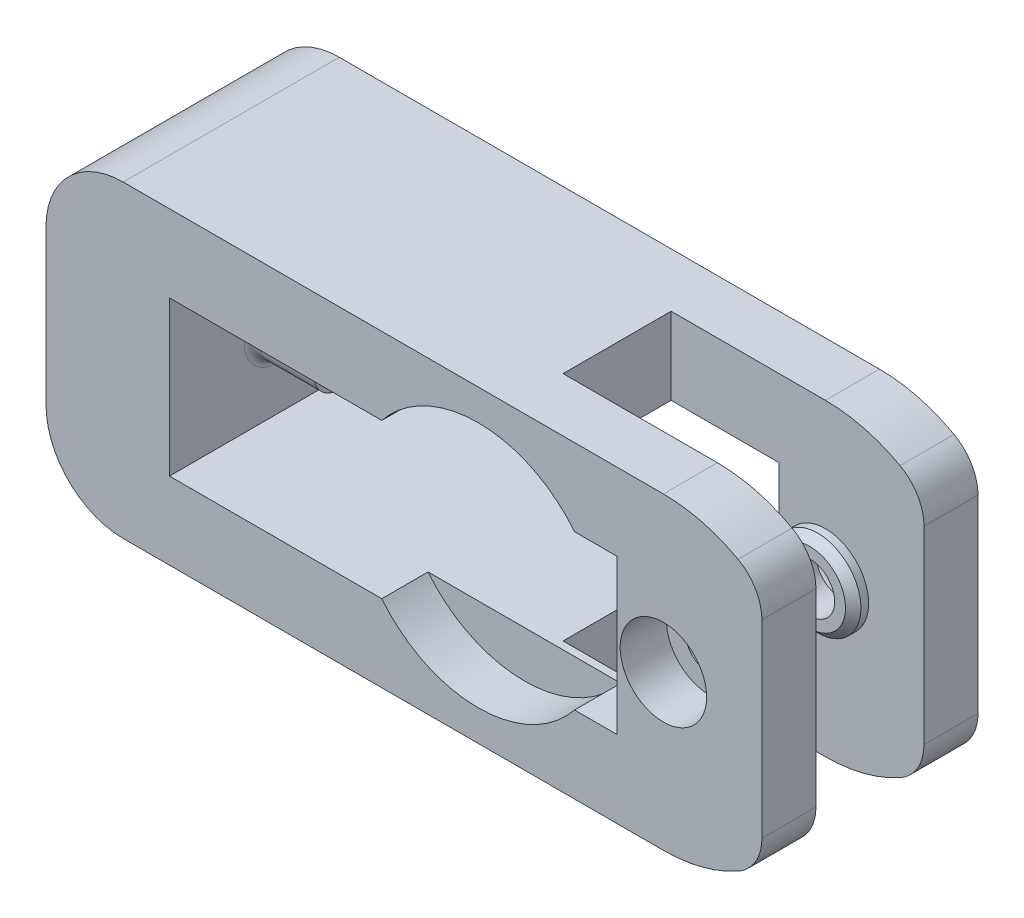
from build123d import *

# Parameters (mm, degrees)
Y_KSEKLIK_EKSTR_ZYON1_DEPTH = 14
RADYUS1_R                   = 5
IZIM3_W                     = 10
IZIM3_H                     = 7
KES_EKSTR_ZYON2_DEPTH       = 20
Y_KSEKLIK_EKSTR_ZYON2_DEPTH = 3.5
Y_KSEKLIK_EKSTR_ZYON3_DEPTH = 3.5
IZIM6_R                     = 2.8
IZIM6_R_2                   = 1.6
Y_KSEKLIK_EKSTR_ZYON4_DEPTH = 1
IZIM7_R                     = 2.8
IZIM7_R_2                   = 1.6
Y_KSEKLIK_EKSTR_ZYON5_DEPTH = 1
PAH1_SIZE                   = 0.5
IZIM8_W                     = 29
IZIM8_H                     = 10
KES_EKSTR_ZYON3_DEPTH       = 15
IZIM9_R                     = 2.8
KES_EKSTR_ZYON5_DEPTH       = 3
KES_EKSTR_ZYON6_DEPTH       = 2.5
IZIM11_R                    = 1.6
KES_EKSTR_ZYON7_DEPTH       = 10
IZIM12_R                    = 1.65
Y_KSEKLIK_EKSTR_ZYON6_DEPTH = 4
RADYUS2_R                   = 0.5
RADYUS5_R                   = 1
RADYUS7_R                   = 3
IZIM15_R                    = 8
KES_EKSTR_ZYON8_DEPTH       = 3


with BuildPart() as part:
    # Çizim1 → Yükseklik-Ekstrüzyon1 (new body)
    with BuildSketch(Plane.XY):
        Polygon((-28.371919233, 20), (11.628080767, 20), (11.628080767, 15), (-20.371919233, 15), (-20.371919233, 5), (11.628080767, 5), (11.628080767, 0), (-28.371919233, 0), align=None)
    extrude(amount=Y_KSEKLIK_EKSTR_ZYON1_DEPTH)

    # Radyus1
    radyus1_edges = [part.edges().sort_by_distance(p)[0] for p in [
        (-28.371919233, 20, 7),
        (-28.371919233, 0, 7),
    ]]
    fillet(radyus1_edges, radius=RADYUS1_R)

    # Çizim3 → Kes-Ekstrüzyon2 (cut)
    with BuildSketch(Plane(origin=(0, 20, 0), x_dir=(1, 0, 0), z_dir=(0, 1, 0))):
        with Locations((6.628080767, -7)):
            Rectangle(IZIM3_W, IZIM3_H)
    extrude(amount=-KES_EKSTR_ZYON2_DEPTH, mode=Mode.SUBTRACT)

    # Çizim4 → Yükseklik-Ekstrüzyon2 (add)
    with BuildSketch(Plane.XY.offset(14)):
        with BuildLine():
            Line((18.011958757, 17.69714894), (18.011958757, 2.30285106))
            ThreePointArc((18.011958757, 2.30285106), (1.628080767, 10), (18.011958757, 17.69714894))
        make_face()
    extrude(amount=-Y_KSEKLIK_EKSTR_ZYON2_DEPTH)

    # Çizim5 → Yükseklik-Ekstrüzyon3 (add)
    with BuildSketch(Plane(origin=(0, 0, 0), x_dir=(-1, 0, 0), z_dir=(0, 0, -1))):
        with BuildLine():
            Line((-18.011958757, 17.69714894), (-18.011958757, 2.30285106))
            ThreePointArc((-18.011958757, 2.30285106), (-1.628080767, 10), (-18.011958757, 17.69714894))
        make_face()
    extrude(amount=-Y_KSEKLIK_EKSTR_ZYON3_DEPTH)

    # Çizim6 → Yükseklik-Ekstrüzyon4 (add)
    with BuildSketch(Plane(origin=(0, 0, 10.5), x_dir=(-1, 0, 0), z_dir=(0, 0, -1))):
        with Locations((-11.628080767, 10)):
            Circle(IZIM6_R)
        with Locations((-11.628080767, 10)):
            Circle(IZIM6_R_2, mode=Mode.SUBTRACT)
    extrude(amount=Y_KSEKLIK_EKSTR_ZYON4_DEPTH)

    # Çizim7 → Yükseklik-Ekstrüzyon5 (add)
    with BuildSketch(Plane.XY.offset(3.5)):
        with Locations((11.628080767, 10)):
            Circle(IZIM7_R)
        with Locations((11.628080767, 10)):
            Circle(IZIM7_R_2, mode=Mode.SUBTRACT)
    extrude(amount=Y_KSEKLIK_EKSTR_ZYON5_DEPTH)

    # Pah1
    pah1_edges = [part.edges().sort_by_distance(p)[0] for p in [
        (14.428080767, 10, 9.5),
        (8.828080767, 10, 4.5),
    ]]
    chamfer(pah1_edges, length=PAH1_SIZE)

    # Çizim8 → Kes-Ekstrüzyon3 (cut)
    with BuildSketch(Plane.XY.offset(14)):
        with Locations((-5.871919233, 10)):
            Rectangle(IZIM8_W, IZIM8_H)
    extrude(amount=-KES_EKSTR_ZYON3_DEPTH, mode=Mode.SUBTRACT)

    # Çizim9 → Kes-Ekstrüzyon5 (cut)
    with BuildSketch(Plane.XY.offset(14)):
        with Locations((11.628080767, 10)):
            Circle(IZIM9_R)
    extrude(amount=-KES_EKSTR_ZYON5_DEPTH, mode=Mode.SUBTRACT)

    # Çizim10 → Kes-Ekstrüzyon6 (cut)
    with BuildSketch(Plane(origin=(0, 0, 0), x_dir=(-1, 0, 0), z_dir=(0, 0, -1))):
        Polygon((-11.628080767, 13.15), (-14.356060789, 11.575), (-14.356060789, 8.425), (-11.628080767, 6.85), (-8.900100745, 8.425), (-8.900100745, 11.575), align=None)
    extrude(amount=-KES_EKSTR_ZYON6_DEPTH, mode=Mode.SUBTRACT)

    # Çizim11 → Kes-Ekstrüzyon7 (cut)
    with BuildSketch(Plane.XY.offset(11)):
        with Locations((11.628080767, 10)):
            Circle(IZIM11_R)
    extrude(amount=-KES_EKSTR_ZYON7_DEPTH, mode=Mode.SUBTRACT)

    # Çizim12 → Yükseklik-Ekstrüzyon6 (add)
    with BuildSketch(Plane(origin=(-20.371919233, 0, 0), x_dir=(0, 0, -1), z_dir=(1, 0, 0))):
        with Locations((-7, 10)):
            Circle(IZIM12_R)
    extrude(amount=Y_KSEKLIK_EKSTR_ZYON6_DEPTH)

    # Radyus2
    radyus2_edges = [part.edges().sort_by_distance(p)[0] for p in [
        (-20.371919233, 10, 8.65),
    ]]
    fillet(radyus2_edges, radius=RADYUS2_R)

    # Çizim14 → Kes-Döndür1 (revolve, cut)
    with BuildSketch(Plane(origin=(0, 0, 7), x_dir=(-1, 0, 0), z_dir=(0, 0, -1))):
        with BuildLine():
            Line((32.371919233, 16), (32.371919233, 4))
            ThreePointArc((32.371919233, 4), (38.371919233, 10), (32.371919233, 16))
        make_face()
    revolve(axis=Axis((-32.371919233, 16, 7), (0, -1, 0)), mode=Mode.SUBTRACT)

    # Radyus5
    radyus5_edges = [part.edges().sort_by_distance(p)[0] for p in [
        (-28.371919233, 10, 11.472135955),
    ]]
    fillet(radyus5_edges, radius=RADYUS5_R)

    # Radyus7
    radyus7_edges = [part.edges().sort_by_distance(p)[0] for p in [
        (18.011958757, 2.30285106, 12.25),
        (18.011958757, 17.69714894, 12.25),
        (18.011958757, 17.69714894, 1.75),
        (18.011958757, 2.30285106, 1.75),
    ]]
    fillet(radyus7_edges, radius=RADYUS7_R)

    # Çizim15 → Kes-Ekstrüzyon8 (cut)
    with BuildSketch(Plane.XY.offset(14)):
        with Locations((-0.371919233, 10)):
            Circle(IZIM15_R)
    extrude(amount=-KES_EKSTR_ZYON8_DEPTH, mode=Mode.SUBTRACT)


solid = part.part
